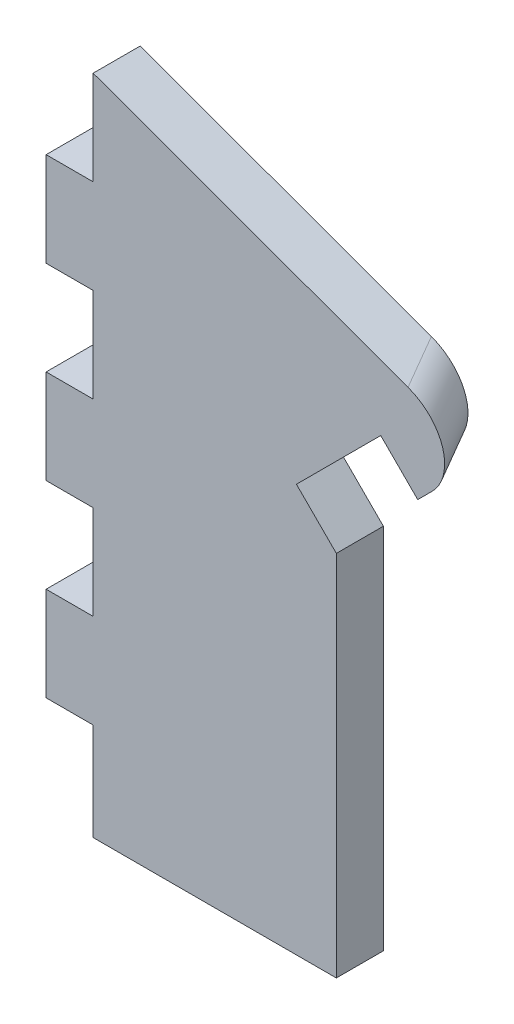
from build123d import *

# Parameters (mm, degrees)
SKETCH1_W           = 119.144328959
SKETCH1_H           = 140.724589222
BOSS_EXTRUDE1_DEPTH = 10
SKETCH2_W           = 10
SKETCH2_H           = 20
SKETCH2_H_2         = 20.724589222
CUT_EXTRUDE1_DEPTH  = 10
CUT_EXTRUDE2_DEPTH  = 10
CUT_EXTRUDE6_DEPTH  = 150
CUT_EXTRUDE7_REACH  = 169.502
SKETCH9_W           = 10
SKETCH9_H           = 25.346761212
SKETCH10_W          = 31.040737262
SKETCH10_H          = 31.620202264
CUT_EXTRUDE8_DEPTH  = 150
FILLET1_R           = 10


with BuildPart() as part:
    # Sketch1 → Boss-Extrude1 (new body)
    with BuildSketch(Plane.XY):
        with Locations((59.57216448, 70.362294611)):
            Rectangle(SKETCH1_W, SKETCH1_H)
    extrude(amount=BOSS_EXTRUDE1_DEPTH)

    # Sketch2 → Cut-Extrude1 (cut)
    with BuildSketch(Plane.XY.offset(10)):
        with Locations((5, 50.724589222)):
            Rectangle(SKETCH2_W, SKETCH2_H)
        with Locations((5, 90.724589222)):
            Rectangle(SKETCH2_W, SKETCH2_H)
        with Locations((5, 10.362294611)):
            Rectangle(SKETCH2_W, SKETCH2_H_2)
        with Locations((5, 130.724589222)):
            Rectangle(SKETCH2_W, SKETCH2_H)
    extrude(amount=-CUT_EXTRUDE1_DEPTH, mode=Mode.SUBTRACT)

    # Sketch4 → Cut-Extrude2 (cut)
    with BuildSketch(Plane.XY.offset(10)):
        Polygon((10, 140.724589222), (119.144328959, 100.999302242), (119.144328959, 140.724589222), align=None)
    extrude(amount=-CUT_EXTRUDE2_DEPTH, mode=Mode.SUBTRACT)

    # Sketch7 → Cut-Extrude6 (cut)
    with BuildSketch(Plane.XY.offset(10)):
        Polygon((76.127978338, 92.605170498), (93.75776849, 110.239254603), (119.144328959, 100.999302242), (119.144328959, 0), (61.696670809, 0), (61.696670809, 78.170348045), align=None)
    extrude(amount=-CUT_EXTRUDE6_DEPTH, mode=Mode.SUBTRACT)

    # Cut-Extrude7: up to this plane
    cut_extrude7_end = Plane(origin=(241.768645896, -65.518758289, 505.407022073), z_dir=(0.6359690231741637, -0.635814162767, -0.4373599798653267))
    # Sketch9 → Cut-Extrude7 (cut, up to the surface)
    with BuildSketch(Plane(origin=(-8.22932488, 8.227321014, 0), x_dir=(0, 0, -1), z_dir=(0.7071928777614668, -0.7070206741273237, 0)), mode=Mode.PRIVATE) as cut_extrude7_sk1:
        with Locations((-5, 111.575715782)):
            Rectangle(SKETCH9_W, SKETCH9_H)
    cut_extrude7_tool1 = split(extrude(cut_extrude7_sk1.sketch, amount=-CUT_EXTRUDE7_REACH, mode=Mode.PRIVATE), bisect_by=cut_extrude7_end, keep=Keep.BOTH, mode=Mode.PRIVATE)
    add(cut_extrude7_tool1.solids().sort_by_distance((70.657013, 87.132873, 5))[0], mode=Mode.SUBTRACT)

    # Sketch10 → Cut-Extrude8 (cut)
    with BuildSketch(Plane(origin=(-9.939992949, 9.937572531, 6.835796961), x_dir=(-0.30929786277865773, 0.30922254780069597, -0.8992865216449099), z_dir=(0.6359690231741634, -0.6358141627670002, -0.4373599798653268))):
        with Locations((3.372258752, 133.362557089)):
            Rectangle(SKETCH10_W, SKETCH10_H)
    extrude(amount=CUT_EXTRUDE8_DEPTH, mode=Mode.SUBTRACT)

    # Fillet1
    fillet1_edges = [part.edges().sort_by_distance(p)[0] for p in [
        (90.324191509, 111.488974422, 5),
    ]]
    fillet(fillet1_edges, radius=FILLET1_R)


solid = part.part
